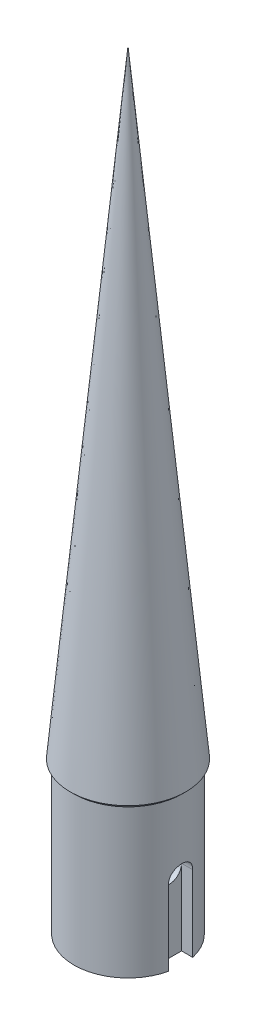
from build123d import *

# Parameters (mm, degrees)
SKETCH1_R               = 8.895
BOSS_EXTRUDE1_DEPTH     = 25
CUT_EXTRUDE1_DEPTH      = 12.5
SKETCH3_R               = 1.984375
CUT_EXTRUDE2_DEPTH      = 9.895
CUT_EXTRUDE2_DEPTH_BACK = 9.895
CHAMFER1_SIZE           = 0.6


with BuildPart() as part:
    # Sketch1 → Boss-Extrude1 (new body)
    with BuildSketch(Plane(origin=(0, 0, 0), x_dir=(1, 0, 0), z_dir=(0, 1, 0))):
        Circle(SKETCH1_R)
    extrude(amount=-BOSS_EXTRUDE1_DEPTH)

    # Sketch2 → Cut-Extrude1 (cut)
    with BuildSketch(Plane.XZ.offset(25)):
        with BuildLine():
            Line((-6.83125, 1.984375), (-6.83125, -1.984375))
            Line((-6.83125, -1.984375), (-8.670829306, -1.984375))
            ThreePointArc((-8.670829306, -1.984375), (-8.895, 0), (-8.670829306, 1.984375))
            Line((-8.670829306, 1.984375), (-6.83125, 1.984375))
        make_face()
    cut_extrude1 = extrude(amount=-CUT_EXTRUDE1_DEPTH, mode=Mode.SUBTRACT)

    # Mirror1: Cut-Extrude1 across plane
    add(cut_extrude1.mirror(Plane(origin=(0, 0, 0), x_dir=(0, 0, 1), z_dir=(1, 0, 0))), mode=Mode.SUBTRACT)

    # Sketch3 → Cut-Extrude2 (cut, two sides)
    with BuildSketch(Plane(origin=(0, 0, 0), x_dir=(0, 0, -1), z_dir=(1, 0, 0))) as cut_extrude2_sk:
        with Locations((0, -12.5)):
            Circle(SKETCH3_R)
    extrude(amount=CUT_EXTRUDE2_DEPTH, mode=Mode.SUBTRACT)
    extrude(cut_extrude2_sk.sketch, amount=-CUT_EXTRUDE2_DEPTH_BACK, mode=Mode.SUBTRACT)

    # Sketch4 → Revolve1 (revolve)
    with BuildSketch(Plane.XY):
        Polygon((0, 0), (9.5, 0), (0, 101.6), align=None)
    revolve(axis=Axis((0, 101.6, 0), (0, -1, 0)))

    # Chamfer1
    chamfer1_edges = [part.edges().sort_by_distance(p)[0] for p in [
        (-8.895, 0, 0),
    ]]
    chamfer(chamfer1_edges, length=CHAMFER1_SIZE)


solid = part.part
